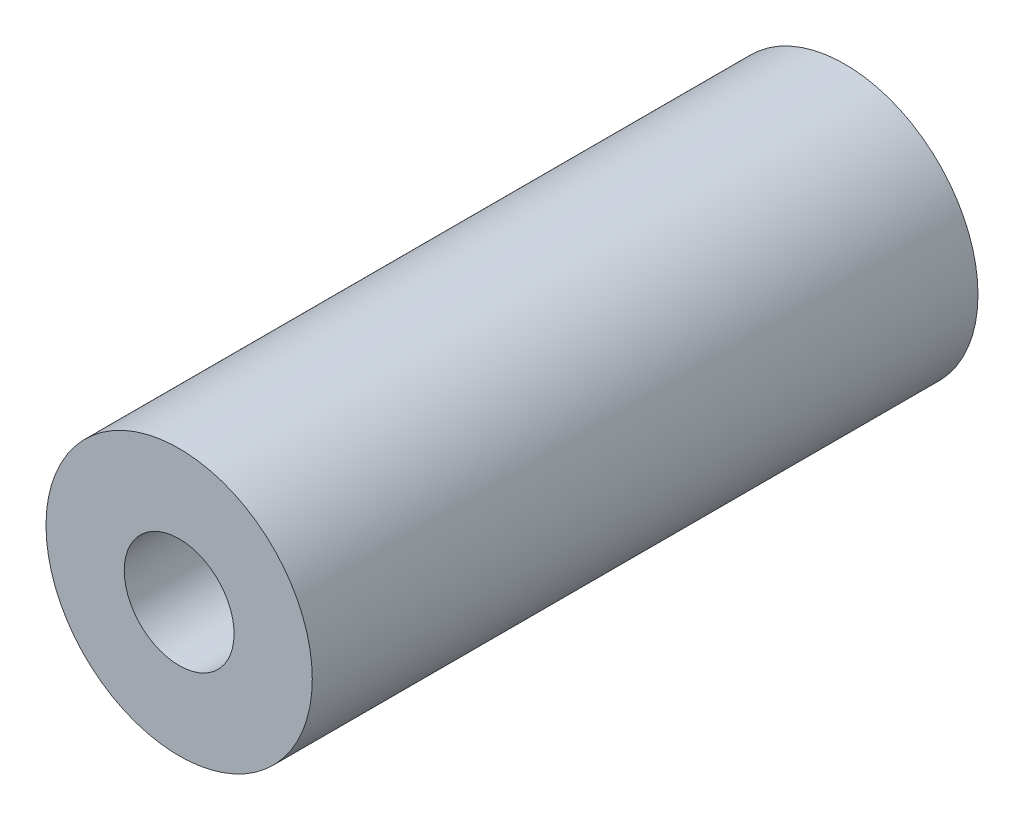
from build123d import *

# Parameters (mm, degrees)
SKETCH1_R                       = 4
BOSS_EXTRUDE1_DEPTH             = 20
TAP_DRILL_FOR_M4X0_7_TAP1_D     = 3.3
TAP_DRILL_FOR_M4X0_7_TAP1_DEPTH = 20


with BuildPart() as part:
    # Sketch1 → Boss-Extrude1 (new body)
    with BuildSketch(Plane.XY):
        Circle(SKETCH1_R)
    extrude(amount=BOSS_EXTRUDE1_DEPTH)

    # Tap Drill for M4x0.7 Tap1
    with Locations(Plane(origin=(0, 0, 0), x_dir=(-1, 0, 0), z_dir=(0, 0, -1))):
        with Locations((0, 0)):
            Hole(TAP_DRILL_FOR_M4X0_7_TAP1_D / 2, depth=TAP_DRILL_FOR_M4X0_7_TAP1_DEPTH)


solid = part.part
